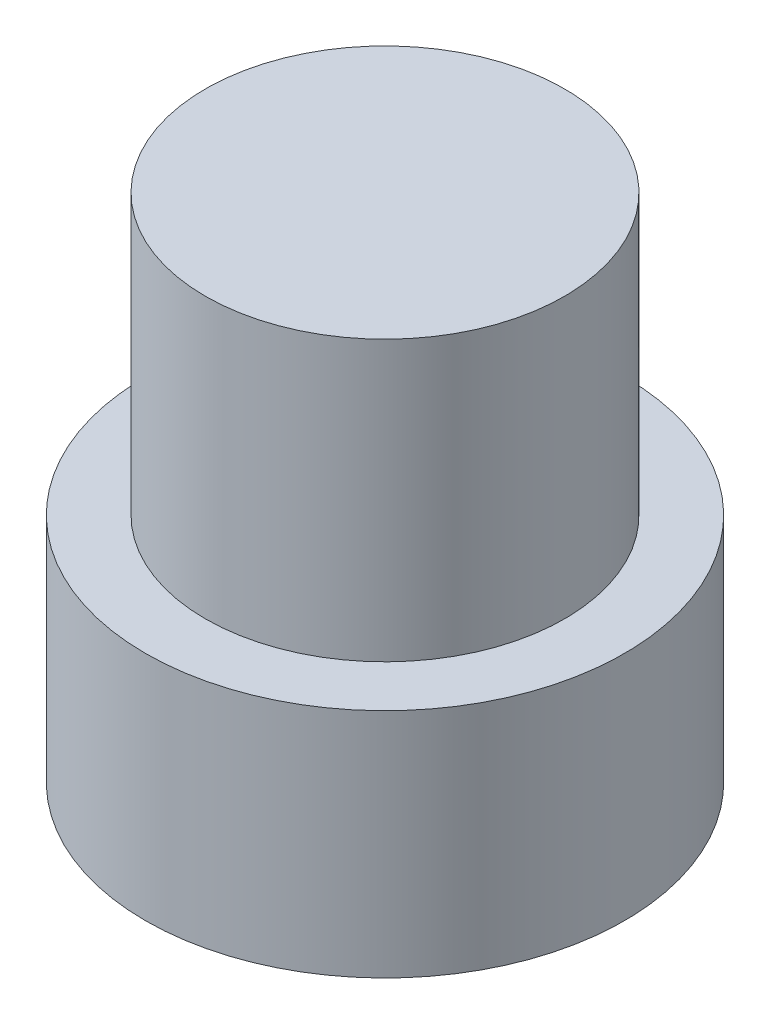
from build123d import *

# Parameters (mm, degrees)
SKETCH1_R           = 6
BOSS_EXTRUDE2_DEPTH = 5.8
SKETCH5_R           = 4.5
BOSS_EXTRUDE3_DEPTH = 7
SKETCH6_R           = 2.5
BOSS_EXTRUDE4_DEPTH = 1.5


with BuildPart() as part:
    # Sketch1 → Boss-Extrude2 (new body)
    with BuildSketch(Plane(origin=(0, 0, 0), x_dir=(1, 0, 0), z_dir=(0, 1, 0))):
        Circle(SKETCH1_R)
    extrude(amount=-BOSS_EXTRUDE2_DEPTH)

    # Sketch5 → Boss-Extrude3 (add)
    with BuildSketch(Plane(origin=(0, 0, 0), x_dir=(-1, 0, 0), z_dir=(0, 1, 0))):
        Circle(SKETCH5_R)
    extrude(amount=BOSS_EXTRUDE3_DEPTH)

    # Sketch6 → Boss-Extrude4 (add)
    with BuildSketch(Plane.XZ.offset(5.8)):
        Circle(SKETCH6_R)
    extrude(amount=BOSS_EXTRUDE4_DEPTH)


solid = part.part
